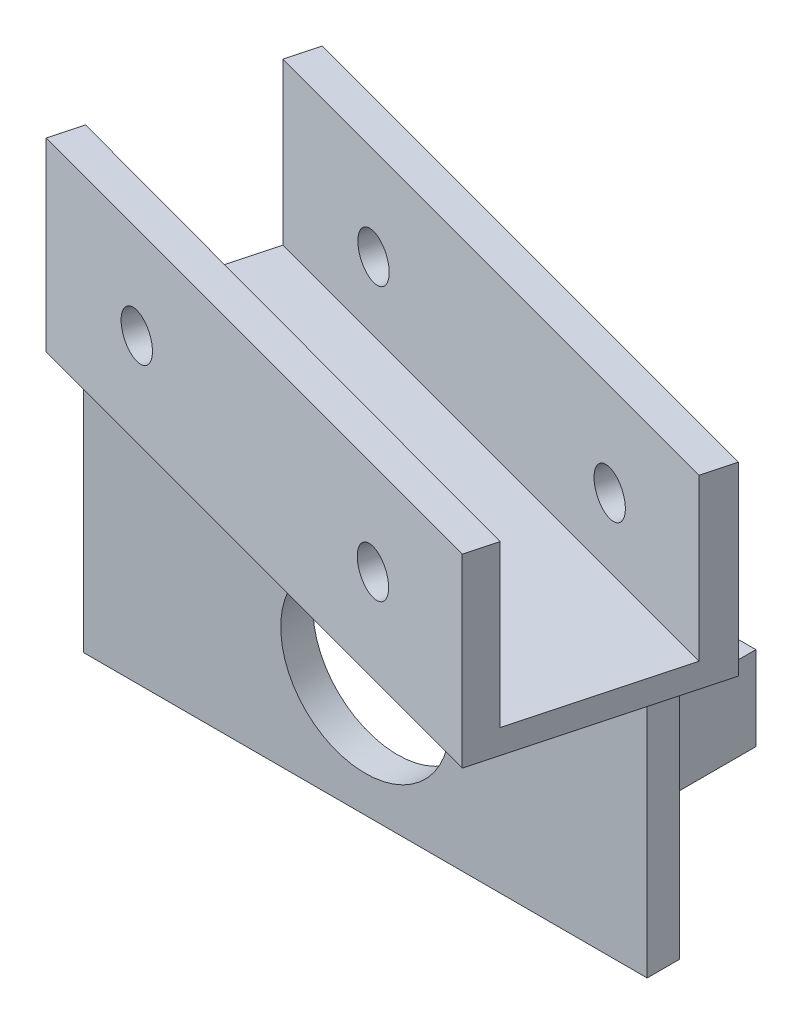
from build123d import *

# Parameters (mm, degrees)
SKETCH1_W           = 70
SKETCH1_H           = 30
SKETCH1_R           = 10.5
BOSS_EXTRUDE1_DEPTH = 4
SKETCH3_W           = 8.150987667
SKETCH3_H           = 10.43538234
SKETCH3_W_2         = 6.820916115
SKETCH3_H_2         = 20
BOSS_EXTRUDE2_DEPTH = 17
SKETCH4_R           = 1
CUT_EXTRUDE1_DEPTH  = 17
BOSS_EXTRUDE4_DEPTH = 3
BOSS_EXTRUDE5_DEPTH = 20
SKETCH10_R          = 2.75
CUT_EXTRUDE2_DEPTH  = 47.267747797


with BuildPart() as part:
    # Sketch1 → Boss-Extrude1 (new body)
    with BuildSketch(Plane.XY):
        with Locations((35, -15)):
            Rectangle(SKETCH1_W, SKETCH1_H)
        with Locations((35, -15)):
            Circle(SKETCH1_R, mode=Mode.SUBTRACT)
    extrude(amount=BOSS_EXTRUDE1_DEPTH)

    # Sketch3 → Boss-Extrude2 (add)
    with BuildSketch(Plane(origin=(0, 0, 0), x_dir=(-1, 0, 0), z_dir=(0, 0, -1))):
        with Locations((-58.424506167, -14.156074174)):
            Rectangle(SKETCH3_W, SKETCH3_H)
        with Locations((-10.910458058, -15)):
            Rectangle(SKETCH3_W_2, SKETCH3_H_2)
    extrude(amount=BOSS_EXTRUDE2_DEPTH)

    # Sketch4 → Cut-Extrude1 (cut)
    with BuildSketch(Plane(origin=(0, 0, -17), x_dir=(-1, 0, 0), z_dir=(0, 0, -1))):
        with Locations((-58.5, -14.289099526)):
            Circle(SKETCH4_R)
        with Locations((-11.5, -7)):
            Circle(SKETCH4_R)
        with Locations((-11.5, -23)):
            Circle(SKETCH4_R)
    extrude(amount=-CUT_EXTRUDE1_DEPTH, mode=Mode.SUBTRACT)

    # Sketch7 → Boss-Extrude4 (add)
    with BuildSketch(Plane(origin=(0, 0, 0), x_dir=(1, 0, 0), z_dir=(0, 1, 0))):
        Polygon((-4.630368757, -4), (65.950788783, -22.912164164), (73.197722046, 4.133758972), (2.616564506, 23.045923136), align=None)
    extrude(amount=BOSS_EXTRUDE4_DEPTH)

    # Sketch9 → Boss-Extrude5 (add)
    with BuildSketch(Plane(origin=(0, 3, 0), x_dir=(1, 0, 0), z_dir=(0, 1, 0))):
        Polygon((-4.630368757, -4), (65.950788783, -22.912164164), (66.943950204, -19.205635281), (-3.595092577, -0.136296695), align=None)
        Polygon((2.616564506, 23.045923136), (1.581288325, 19.182219831), (72.162445865, 0.270055667), (73.197722046, 4.133758972), align=None)
    extrude(amount=BOSS_EXTRUDE5_DEPTH)

    # Sketch10 → Cut-Extrude2 (cut, through all)
    with BuildSketch(Plane(origin=(5.936757371, 0, -22.156280139), x_dir=(-0.965925826, 0, -0.258819045), z_dir=(0.258819045, 0, -0.965925826))):
        with Locations((-53.953749554, 11.5)):
            Circle(SKETCH10_R)
        with Locations((-12.488324975, 11.5)):
            Circle(SKETCH10_R)
    extrude(amount=-CUT_EXTRUDE2_DEPTH, mode=Mode.SUBTRACT)


solid = part.part
